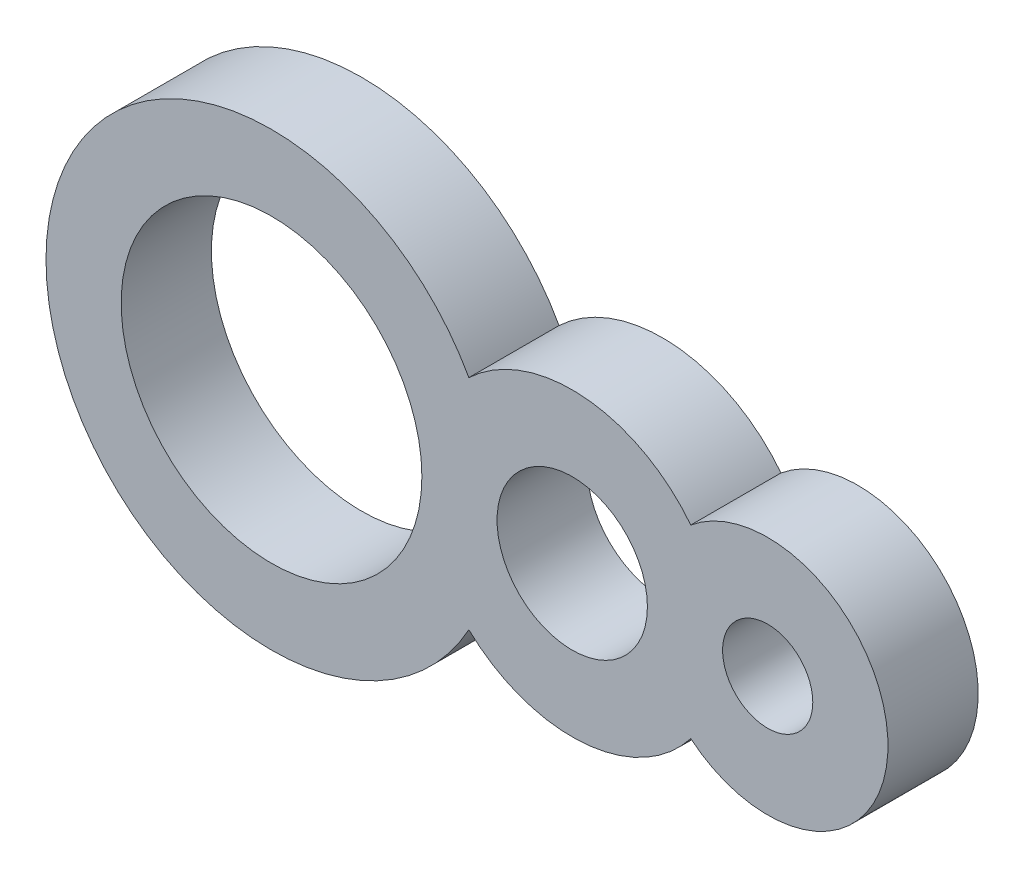
from build123d import *

# Parameters (mm, degrees)
SKETCH1_R           = 5
SKETCH1_R_2         = 2.5
SKETCH1_R_3         = 1.5
BOSS_EXTRUDE1_DEPTH = 3


with BuildPart() as part:
    # Sketch1 → Boss-Extrude1 (new body)
    with BuildSketch(Plane.XY):
        with BuildLine():
            ThreePointArc((6.5625, 3.630921887), (-7.5, 0), (6.5625, -3.630921887))
            ThreePointArc((6.5625, -3.630921887), (10.375304148, -4.985894784), (13.942307692, -3.075420306))
            ThreePointArc((13.942307692, -3.075420306), (20.5, 0), (13.942307692, 3.075420306))
            ThreePointArc((13.942307692, 3.075420306), (10.375304148, 4.985894784), (6.5625, 3.630921887))
        make_face()
        Circle(SKETCH1_R, mode=Mode.SUBTRACT)
        with Locations((10, 0)):
            Circle(SKETCH1_R_2, mode=Mode.SUBTRACT)
        with Locations((16.5, 0)):
            Circle(SKETCH1_R_3, mode=Mode.SUBTRACT)
    extrude(amount=BOSS_EXTRUDE1_DEPTH)


solid = part.part
